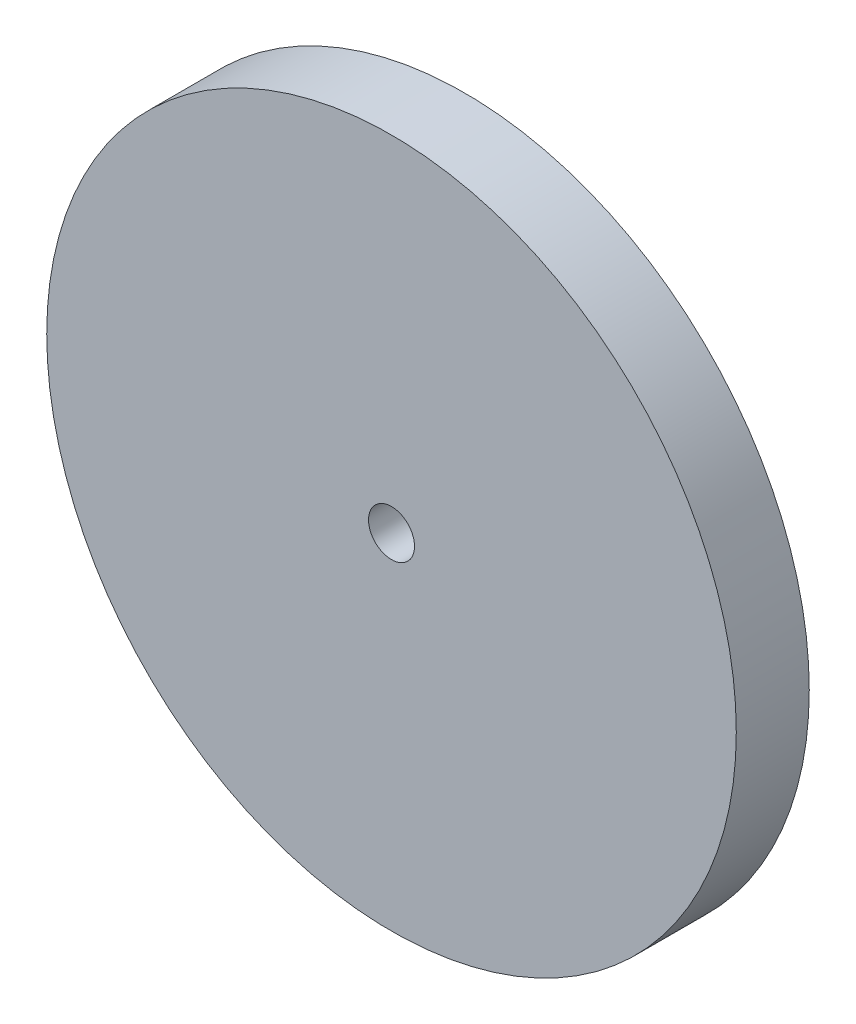
from build123d import *

# Parameters (mm, degrees)
SKETCH1_R           = 15
BOSS_EXTRUDE1_DEPTH = 3.175
SKETCH2_R           = 1
CUT_EXTRUDE1_DEPTH  = 3.175


with BuildPart() as part:
    # Sketch1 → Boss-Extrude1 (new body)
    with BuildSketch(Plane.XY):
        Circle(SKETCH1_R)
    extrude(amount=BOSS_EXTRUDE1_DEPTH)

    # Sketch2 → Cut-Extrude1 (cut)
    with BuildSketch(Plane.XY.offset(3.175)):
        Circle(SKETCH2_R)
    extrude(amount=-CUT_EXTRUDE1_DEPTH, mode=Mode.SUBTRACT)


solid = part.part
